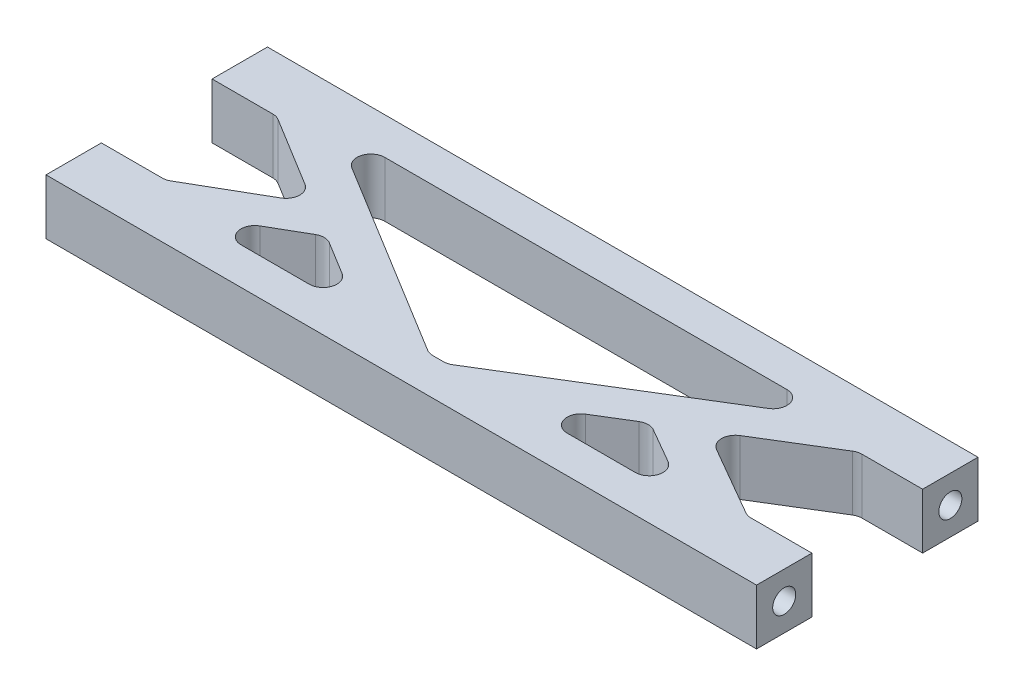
from build123d import *

# Parameters (mm, degrees)
SKETCH1_W                   = 77
SKETCH1_H                   = 24
BOSS_EXTRUDE1_DEPTH         = 6
CUT_EXTRUDE1_REACH          = 8
TAP_DRILL_FOR_M3_TAP1_D     = 2.5
TAP_DRILL_FOR_M3_TAP1_DEPTH = 10
TAP_DRILL_FOR_M3_TAP1_TIP   = 0.751075774
TAP_DRILL_FOR_M3_TAP2_D     = 2.5
TAP_DRILL_FOR_M3_TAP2_DEPTH = 10
TAP_DRILL_FOR_M3_TAP2_TIP   = 0.751075774
FILLET1_R                   = 1.5


with BuildPart() as part:
    # Sketch1 → Boss-Extrude1 (new body)
    with BuildSketch(Plane(origin=(0, 0, 0), x_dir=(1, 0, 0), z_dir=(0, 1, 0))):
        with Locations((38.5, 12)):
            Rectangle(SKETCH1_W, SKETCH1_H)
    extrude(amount=BOSS_EXTRUDE1_DEPTH)

    # Sketch2 → Cut-Extrude1 (cut, up to next)
    with BuildSketch(Plane(origin=(0, 6, 0), x_dir=(1, 0, 0), z_dir=(0, 1, 0)), mode=Mode.PRIVATE) as cut_extrude1_sk1:
        Polygon((0, 18), (7, 18), (17.082489299, 11.821127911), (7, 6), (0, 6), align=None)
    cut_extrude1_tool1 = extrude(cut_extrude1_sk1.sketch, amount=-CUT_EXTRUDE1_REACH, mode=Mode.PRIVATE) & part.part
    add(cut_extrude1_tool1.solids().sort_by_distance((6.372388, 6, -11.975038))[0], mode=Mode.SUBTRACT)
    # Sketch2 → Cut-Extrude1 (cut, up to next)
    with BuildSketch(Plane(origin=(0, 6, 0), x_dir=(1, 0, 0), z_dir=(0, 1, 0)), mode=Mode.PRIVATE) as cut_extrude1_sk2:
        Polygon((11.391702814, 20), (65.608297186, 20), (39.5, 4), (37.5, 4), align=None)
    cut_extrude1_tool2 = extrude(cut_extrude1_sk2.sketch, amount=-CUT_EXTRUDE1_REACH, mode=Mode.PRIVATE) & part.part
    add(cut_extrude1_tool2.solids().sort_by_distance((38.5, 6, -14.476924))[0], mode=Mode.SUBTRACT)
    # Sketch2 → Cut-Extrude1 (cut, up to next)
    with BuildSketch(Plane(origin=(0, 6, 0), x_dir=(1, 0, 0), z_dir=(0, 1, 0)), mode=Mode.PRIVATE) as cut_extrude1_sk3:
        Polygon((77, 18), (70, 18), (59.917510701, 11.821127911), (70, 6), (77, 6), align=None)
    cut_extrude1_tool3 = extrude(cut_extrude1_sk3.sketch, amount=-CUT_EXTRUDE1_REACH, mode=Mode.PRIVATE) & part.part
    add(cut_extrude1_tool3.solids().sort_by_distance((70.627612, 6, -11.975038))[0], mode=Mode.SUBTRACT)
    # Sketch2 → Cut-Extrude1 (cut, up to next)
    with BuildSketch(Plane(origin=(0, 6, 0), x_dir=(1, 0, 0), z_dir=(0, 1, 0)), mode=Mode.PRIVATE) as cut_extrude1_sk4:
        Polygon((20.963241239, 9.442878935), (11.535898385, 4), (29.844760038, 4), align=None)
    cut_extrude1_tool4 = extrude(cut_extrude1_sk4.sketch, amount=-CUT_EXTRUDE1_REACH, mode=Mode.PRIVATE) & part.part
    add(cut_extrude1_tool4.solids().sort_by_distance((20.7813, 6, -5.814293))[0], mode=Mode.SUBTRACT)
    # Sketch2 → Cut-Extrude1 (cut, up to next)
    with BuildSketch(Plane(origin=(0, 6, 0), x_dir=(1, 0, 0), z_dir=(0, 1, 0)), mode=Mode.PRIVATE) as cut_extrude1_sk5:
        Polygon((47.155239962, 4), (56.036758761, 9.442878935), (65.464101615, 4), align=None)
    cut_extrude1_tool5 = extrude(cut_extrude1_sk5.sketch, amount=-CUT_EXTRUDE1_REACH, mode=Mode.PRIVATE) & part.part
    add(cut_extrude1_tool5.solids().sort_by_distance((56.2187, 6, -5.814293))[0], mode=Mode.SUBTRACT)

    # Tap Drill for M3 Tap1
    with Locations(Plane.ZY):
        with Locations((-21, 3), (-3, 3)):
            Hole(TAP_DRILL_FOR_M3_TAP1_D / 2, depth=TAP_DRILL_FOR_M3_TAP1_DEPTH)
            with Locations((0, 0, -(TAP_DRILL_FOR_M3_TAP1_DEPTH + TAP_DRILL_FOR_M3_TAP1_TIP / 2))):  # 118° drill point
                Cone(0, TAP_DRILL_FOR_M3_TAP1_D / 2, TAP_DRILL_FOR_M3_TAP1_TIP, mode=Mode.SUBTRACT)

    # Tap Drill for M3 Tap2
    with Locations(Plane(origin=(77, 0, 0), x_dir=(0, 0, -1), z_dir=(1, 0, 0))):
        with Locations((3, 3), (21, 3)):
            Hole(TAP_DRILL_FOR_M3_TAP2_D / 2, depth=TAP_DRILL_FOR_M3_TAP2_DEPTH)
            with Locations((0, 0, -(TAP_DRILL_FOR_M3_TAP2_DEPTH + TAP_DRILL_FOR_M3_TAP2_TIP / 2))):  # 118° drill point
                Cone(0, TAP_DRILL_FOR_M3_TAP2_D / 2, TAP_DRILL_FOR_M3_TAP2_TIP, mode=Mode.SUBTRACT)

    # Fillet1
    fillet1_edges = [part.edges().sort_by_distance(p)[0] for p in [
        (7, 3, -18),
        (17.082489299, 3, -11.821127911),
        (7, 3, -6),
        (70, 3, -6),
        (59.917510701, 3, -11.821127911),
        (70, 3, -18),
        (37.5, 3, -4),
        (11.391702814, 3, -20),
        (65.608297186, 3, -20),
        (39.5, 3, -4),
        (20.963241239, 3, -9.442878935),
        (29.844760038, 3, -4),
        (11.535898385, 3, -4),
        (65.464101615, 3, -4),
        (47.155239962, 3, -4),
        (56.036758761, 3, -9.442878935),
    ]]
    fillet(fillet1_edges, radius=FILLET1_R)


solid = part.part
